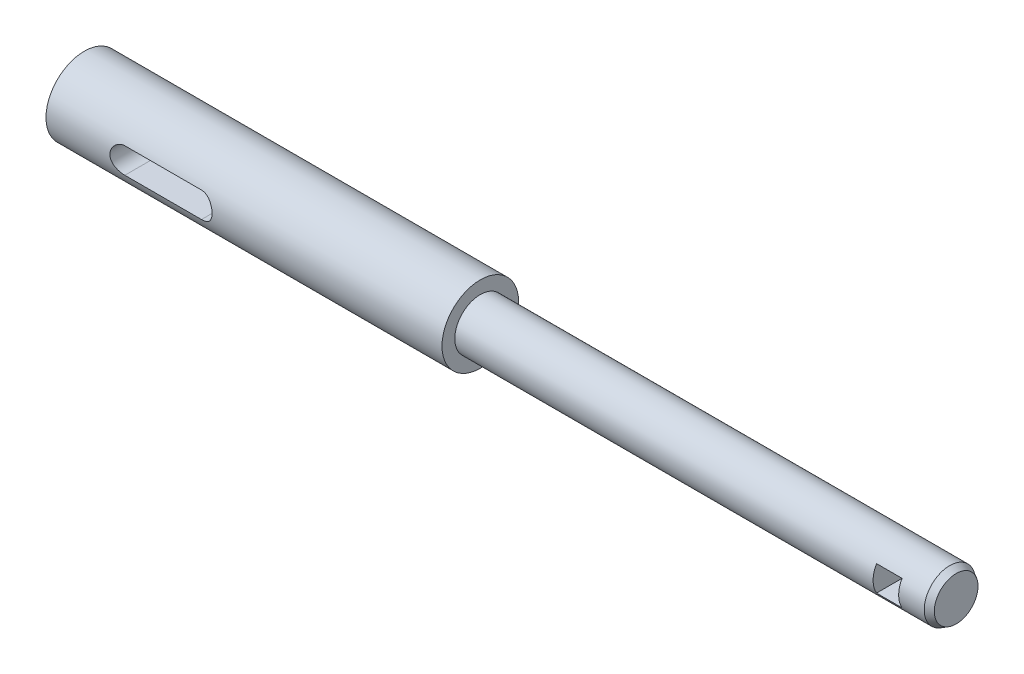
from build123d import *

# Parameters (mm, degrees)
SKETCH1_W               = 62
SKETCH1_H               = 21.285714286
BOSS_EXTRUDE1_DEPTH     = 12
SKETCH3_R               = 4
BOSS_EXTRUDE2_DEPTH     = 74.5
SKETCH4_OUTSIDE_W       = 51.02
SKETCH4_OUTSIDE_H       = 41.734
SKETCH4_OUTSIDE_R       = 6
CUT_EXTRUDE2_DEPTH      = 137.5
SKETCH5_W               = 4
SKETCH5_H               = 4
CUT_EXTRUDE3_DEPTH      = 7
CUT_EXTRUDE3_DEPTH_BACK = 7
CHAMFER1_SIZE           = 1
CHAMFER1_SIZE2          = 0.577350269


with BuildPart() as part:
    # Sketch1 → Boss-Extrude1 (new body)
    with BuildSketch(Plane(origin=(0, 0, 0), x_dir=(1, 0, 0), z_dir=(0, 1, 0))):
        Rectangle(SKETCH1_W, SKETCH1_H)
    extrude(amount=BOSS_EXTRUDE1_DEPTH)

    # Sketch3 → Boss-Extrude2 (add)
    with BuildSketch(Plane(origin=(31, 0, 0), x_dir=(0, 0, -1), z_dir=(1, 0, 0))):
        with Locations((0, 6)):
            Circle(SKETCH3_R)
    extrude(amount=BOSS_EXTRUDE2_DEPTH)

    # Sketch4 outside → Cut-Extrude2 (cut, through all)
    with BuildSketch(Plane.ZY.offset(31)):
        with Locations((0, 6)):
            Rectangle(SKETCH4_OUTSIDE_W, SKETCH4_OUTSIDE_H)
        with Locations((0, 6)):
            Circle(SKETCH4_OUTSIDE_R, mode=Mode.SUBTRACT)
    extrude(amount=-CUT_EXTRUDE2_DEPTH, mode=Mode.SUBTRACT)

    # Sketch5 → Cut-Extrude3 (cut, two sides)
    with BuildSketch(Plane.XY) as cut_extrude3_sk:
        with BuildLine():
            Line((-19, 8), (-7, 8))
            ThreePointArc((-7, 8), (-5, 6), (-7, 4))
            Line((-7, 4), (-19, 4))
            ThreePointArc((-19, 4), (-21, 6), (-19, 8))
        make_face()
        with Locations((98.5, 6)):
            Rectangle(SKETCH5_W, SKETCH5_H)
    extrude(amount=CUT_EXTRUDE3_DEPTH, mode=Mode.SUBTRACT)
    extrude(cut_extrude3_sk.sketch, amount=-CUT_EXTRUDE3_DEPTH_BACK, mode=Mode.SUBTRACT)

    # Chamfer1
    chamfer1_edges = [part.edges().sort_by_distance(p)[0] for p in [
        (105.5, 6, 4),
    ]]
    chamfer1_side = [part.faces().sort_by_distance(p)[0] for p in [
        (68.25, 6, 4),
    ]]
    chamfer(chamfer1_edges, length=CHAMFER1_SIZE, length2=CHAMFER1_SIZE2, reference=chamfer1_side[0])


solid = part.part
